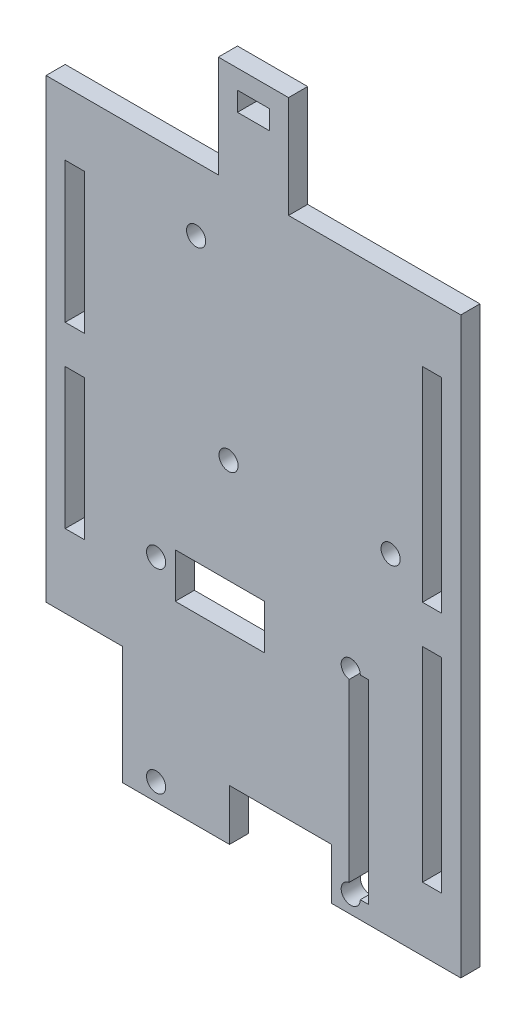
from build123d import *

# Parameters (mm, degrees)
SKETCH1_W           = 65
SKETCH1_H           = 90
BOSS_EXTRUDE1_DEPTH = 3
SKETCH3_R           = 1.5
CUT_EXTRUDE2_DEPTH  = 3
SKETCH4_R           = 1.5
CUT_EXTRUDE3_DEPTH  = 4
SKETCH5_W           = 3
SKETCH5_H           = 32
CUT_EXTRUDE4_DEPTH  = 4
SKETCH6_W           = 3
SKETCH6_H           = 22
CUT_EXTRUDE5_DEPTH  = 4
SKETCH7_W           = 3
SKETCH7_H           = 30.5
SKETCH7_W_2         = 14
SKETCH7_H_2         = 7
SKETCH7_W_3         = 16
SKETCH7_H_3         = 8
CUT_EXTRUDE6_DEPTH  = 4
SKETCH8_W           = 12
SKETCH8_H           = 18.5
CUT_EXTRUDE7_DEPTH  = 4
SKETCH10_W          = 11
SKETCH10_H          = 16
SKETCH10_W_2        = 5
SKETCH10_H_2        = 3
BOSS_EXTRUDE3_DEPTH = 3


with BuildPart() as part:
    # Sketch1 → Boss-Extrude1 (new body)
    with BuildSketch(Plane.XY):
        Rectangle(SKETCH1_W, SKETCH1_H)
    extrude(amount=-BOSS_EXTRUDE1_DEPTH)

    # Sketch3 → Cut-Extrude2 (cut)
    with BuildSketch(Plane.XY):
        with Locations((-8.98, 35)):
            Circle(SKETCH3_R)
        with Locations((-3.9, 7.06)):
            Circle(SKETCH3_R)
        with Locations((21.5, 7.06)):
            Circle(SKETCH3_R)
    extrude(amount=-CUT_EXTRUDE2_DEPTH, mode=Mode.SUBTRACT)

    # Sketch4 → Cut-Extrude3 (cut, through all)
    with BuildSketch(Plane.XY):
        with Locations((-15.25, -42.25)):
            Circle(SKETCH4_R)
        with Locations((-15.25, -11.75)):
            Circle(SKETCH4_R)
        with Locations((15.25, -42.25)):
            Circle(SKETCH4_R)
        with Locations((15.25, -11.75)):
            Circle(SKETCH4_R)
    extrude(amount=-CUT_EXTRUDE3_DEPTH, mode=Mode.SUBTRACT)

    # Sketch5 → Cut-Extrude4 (cut, through all)
    with BuildSketch(Plane.XY):
        with Locations((28, -19)):
            Rectangle(SKETCH5_W, SKETCH5_H)
        with Locations((28, 19)):
            Rectangle(SKETCH5_W, SKETCH5_H)
    extrude(amount=-CUT_EXTRUDE4_DEPTH, mode=Mode.SUBTRACT)

    # Sketch6 → Cut-Extrude5 (cut, through all)
    with BuildSketch(Plane.XY):
        with Locations((-28, -4)):
            Rectangle(SKETCH6_W, SKETCH6_H)
        with Locations((-28, 24)):
            Rectangle(SKETCH6_W, SKETCH6_H)
    extrude(amount=-CUT_EXTRUDE5_DEPTH, mode=Mode.SUBTRACT)

    # Sketch7 → Cut-Extrude6 (cut, through all)
    with BuildSketch(Plane.XY):
        with Locations((16.5, -27)):
            Rectangle(SKETCH7_W, SKETCH7_H)
        with Locations((-5.25, -12.75)):
            Rectangle(SKETCH7_W_2, SKETCH7_H_2)
        with Locations((4.25, -41)):
            Rectangle(SKETCH7_W_3, SKETCH7_H_3)
    extrude(amount=-CUT_EXTRUDE6_DEPTH, mode=Mode.SUBTRACT)

    # Sketch8 → Cut-Extrude7 (cut, through all)
    with BuildSketch(Plane.XY):
        with Locations((-26.5, -35.75)):
            Rectangle(SKETCH8_W, SKETCH8_H)
    extrude(amount=-CUT_EXTRUDE7_DEPTH, mode=Mode.SUBTRACT)

    # Sketch10 → Boss-Extrude3 (add)
    with BuildSketch(Plane.XY):
        with Locations((0, 53)):
            Rectangle(SKETCH10_W, SKETCH10_H)
        with Locations((0, 56.5)):
            Rectangle(SKETCH10_W_2, SKETCH10_H_2, mode=Mode.SUBTRACT)
    extrude(amount=-BOSS_EXTRUDE3_DEPTH)


solid = part.part
